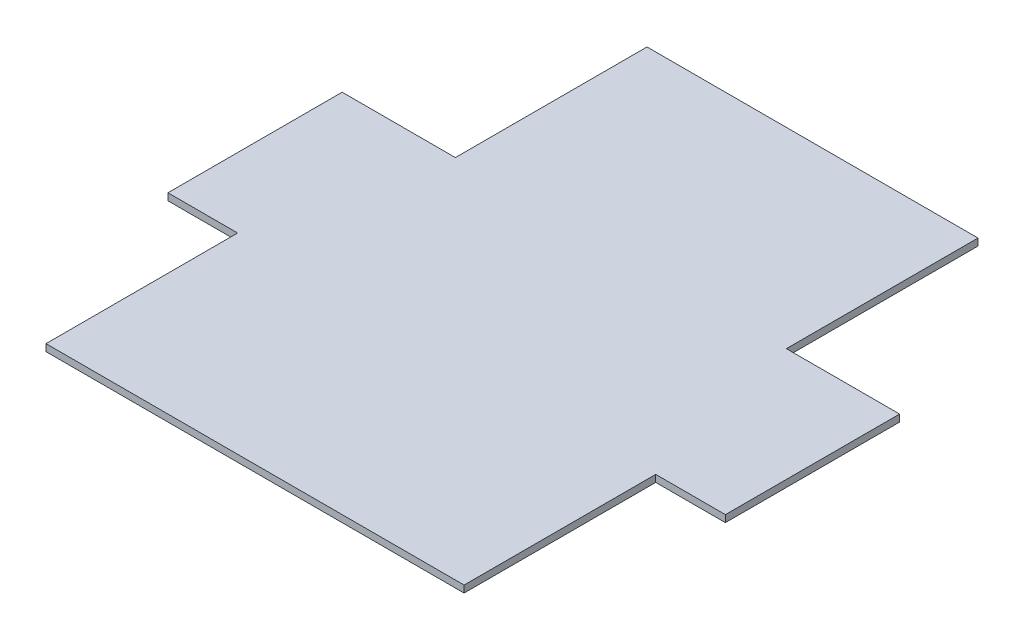
from build123d import *

# Parameters (mm, degrees)
EXTRUDE1_DEPTH = 2


with BuildPart() as part:
    # Sketch1 → Extrude1 (new body)
    with BuildSketch(Plane(origin=(0, 0, 0), x_dir=(1, 0, 0), z_dir=(0, 1, 0))):
        Polygon((-47.5, 80), (47.5, 80), (47.5, 25), (80, 25), (80, -25), (60, -25), (60, -80), (-60, -80), (-60, -25), (-80, -25), (-80, 25), (-47.5, 25), align=None)
    extrude(amount=EXTRUDE1_DEPTH)


solid = part.part
